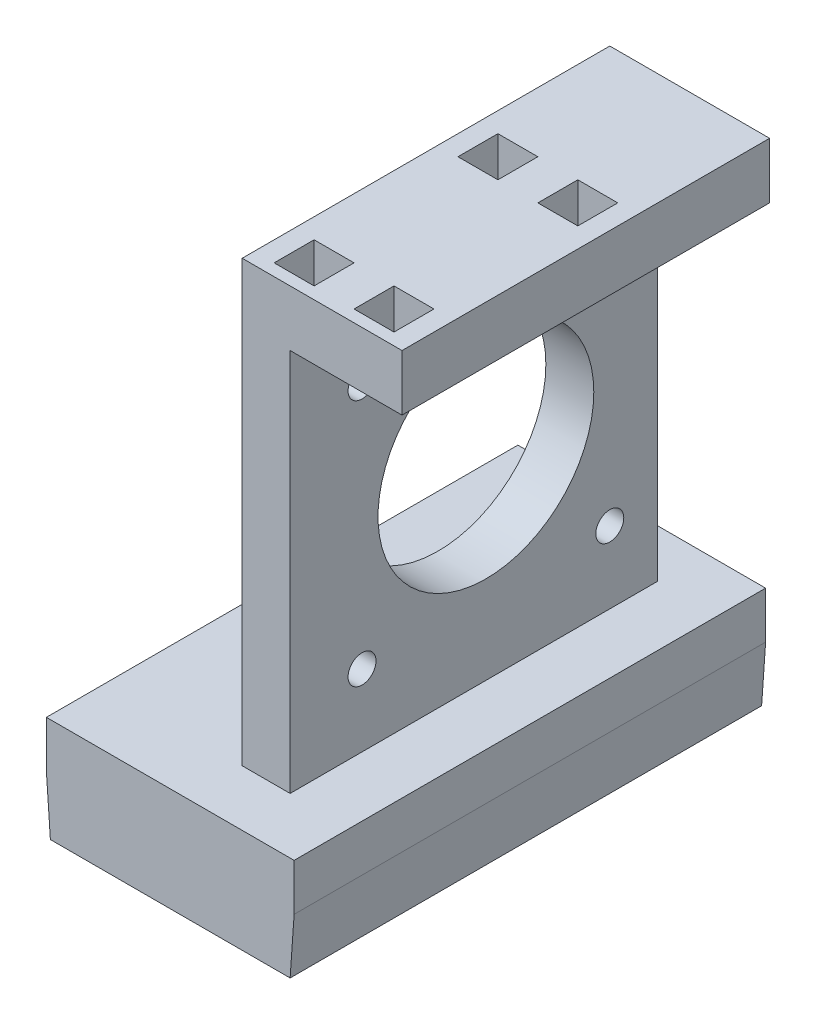
from build123d import *

# Parameters (mm, degrees)
SKETCH1_W           = 26
SKETCH1_H           = 53
SKETCH1_W_2         = 20
SKETCH1_H_2         = 10
BOSS_EXTRUDE1_DEPTH = 5
SKETCH2_W           = 31
SKETCH2_H           = 59
SKETCH2_W_2         = 26
SKETCH2_H_2         = 53
BOSS_EXTRUDE2_DEPTH = 10
SKETCH3_W           = 31
SKETCH3_H           = 59
BOSS_EXTRUDE3_DEPTH = 3
SKETCH4_W           = 6
SKETCH4_H           = 46
BOSS_EXTRUDE4_DEPTH = 55
SKETCH5_R           = 1.75
SKETCH5_R_2         = 13.5
CUT_EXTRUDE1_DEPTH  = 24.5
CHAMFER1_SIZE       = 0.5
CHAMFER1_SIZE2      = 7.150333128
SKETCH6_W           = 46
SKETCH6_H           = 7
BOSS_EXTRUDE5_DEPTH = 14
SKETCH7_W           = 5
SKETCH7_H           = 5
CUT_EXTRUDE2_DEPTH  = 5


with BuildPart() as part:
    # Sketch1 → Boss-Extrude1 (new body)
    with BuildSketch(Plane(origin=(0, 0, 0), x_dir=(1, 0, 0), z_dir=(0, 1, 0))):
        with Locations((-13, 26.5)):
            Rectangle(SKETCH1_W, SKETCH1_H)
        with Locations((-13, 27)):
            Rectangle(SKETCH1_W_2, SKETCH1_H_2, mode=Mode.SUBTRACT)
        with Locations((-13, 43)):
            Rectangle(SKETCH1_W_2, SKETCH1_H_2, mode=Mode.SUBTRACT)
        with Locations((-13, 11)):
            Rectangle(SKETCH1_W_2, SKETCH1_H_2, mode=Mode.SUBTRACT)
    extrude(amount=BOSS_EXTRUDE1_DEPTH)

    # Sketch2 → Boss-Extrude2 (add)
    with BuildSketch(Plane(origin=(0, 5, 0), x_dir=(1, 0, 0), z_dir=(0, 1, 0))):
        with Locations((-13, 26.5)):
            Rectangle(SKETCH2_W, SKETCH2_H)
        with Locations((-13, 26.5)):
            Rectangle(SKETCH2_W_2, SKETCH2_H_2, mode=Mode.SUBTRACT)
    extrude(amount=-BOSS_EXTRUDE2_DEPTH)

    # Sketch3 → Boss-Extrude3 (add)
    with BuildSketch(Plane(origin=(0, 5, 0), x_dir=(1, 0, 0), z_dir=(0, 1, 0))):
        with Locations((-13, 26.5)):
            Rectangle(SKETCH3_W, SKETCH3_H)
    extrude(amount=BOSS_EXTRUDE3_DEPTH)

    # Sketch4 → Boss-Extrude4 (add)
    with BuildSketch(Plane(origin=(0, 8, 0), x_dir=(1, 0, 0), z_dir=(0, 1, 0))):
        with Locations((-8, 27)):
            Rectangle(SKETCH4_W, SKETCH4_H)
    extrude(amount=BOSS_EXTRUDE4_DEPTH)

    # Sketch5 → Cut-Extrude1 (cut, through all)
    with BuildSketch(Plane(origin=(-5, 0, 0), x_dir=(0, 0, -1), z_dir=(1, 0, 0))):
        with Locations((44, 17)):
            Circle(SKETCH5_R)
        with Locations((13, 17)):
            Circle(SKETCH5_R)
        with Locations((13, 48)):
            Circle(SKETCH5_R)
        with Locations((44, 48)):
            Circle(SKETCH5_R)
        with Locations((28.5, 32.5)):
            Circle(SKETCH5_R_2)
    extrude(amount=-CUT_EXTRUDE1_DEPTH, mode=Mode.SUBTRACT)

    # Chamfer1
    chamfer1_edges = [part.edges().sort_by_distance(p)[0] for p in [
        (-28.5, -5, -26.5),
        (2.5, -5, -26.5),
    ]]
    chamfer1_side = [part.faces().sort_by_distance(p)[0] for p in [
        (-13, -5, -55.333516692),
    ]]
    chamfer(chamfer1_edges, length=CHAMFER1_SIZE, length2=CHAMFER1_SIZE2, reference=chamfer1_side[0])

    # Sketch6 → Boss-Extrude5 (add)
    with BuildSketch(Plane(origin=(-5, 0, 0), x_dir=(0, 0, -1), z_dir=(1, 0, 0))):
        with Locations((27, 59.5)):
            Rectangle(SKETCH6_W, SKETCH6_H)
    extrude(amount=BOSS_EXTRUDE5_DEPTH)

    # Sketch7 → Cut-Extrude2 (cut)
    with BuildSketch(Plane(origin=(0, 63, 0), x_dir=(1, 0, 0), z_dir=(0, 1, 0))):
        with Locations((-6, 31)):
            Rectangle(SKETCH7_W, SKETCH7_H)
        with Locations((4, 31)):
            Rectangle(SKETCH7_W, SKETCH7_H)
        with Locations((-6, 8)):
            Rectangle(SKETCH7_W, SKETCH7_H)
        with Locations((4, 8)):
            Rectangle(SKETCH7_W, SKETCH7_H)
    extrude(amount=-CUT_EXTRUDE2_DEPTH, mode=Mode.SUBTRACT)


solid = part.part
